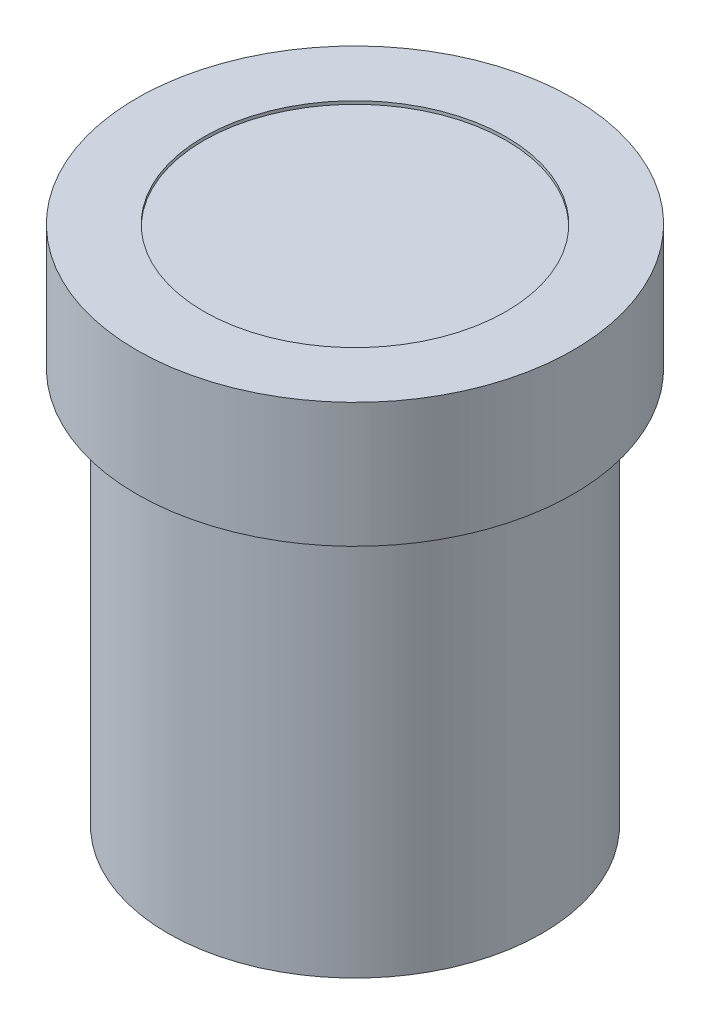
from build123d import *

# Parameters (mm, degrees)
SKETCH1_R           = 6
SKETCH1_R_2         = 2.25
BOSS_EXTRUDE1_DEPTH = 12.7
SKETCH2_R           = 7
SKETCH2_R_2         = 6
SKETCH2_R_3         = 4.85
BOSS_EXTRUDE2_DEPTH = 4
BOSS_EXTRUDE3_START = 3.9
SKETCH2_2_R         = 4.85
BOSS_EXTRUDE3_DEPTH = 0.1


with BuildPart() as part:
    # Sketch1 → Boss-Extrude1 (new body)
    with BuildSketch(Plane(origin=(0, 0, 0), x_dir=(1, 0, 0), z_dir=(0, 1, 0))):
        Circle(SKETCH1_R)
        Circle(SKETCH1_R_2, mode=Mode.SUBTRACT)
    extrude(amount=BOSS_EXTRUDE1_DEPTH)

    # Sketch2 → Boss-Extrude2 (add)
    with BuildSketch(Plane(origin=(0, 12.7, 0), x_dir=(1, 0, 0), z_dir=(0, 1, 0))):
        Circle(SKETCH2_R)
        Circle(SKETCH2_R_2, mode=Mode.SUBTRACT)
        Circle(SKETCH2_R_2)
        Circle(SKETCH2_R_3, mode=Mode.SUBTRACT)
    extrude(amount=BOSS_EXTRUDE2_DEPTH)

    # Sketch2_2 → Boss-Extrude3 (add)
    with BuildSketch(Plane(origin=(0, 12.7, 0), x_dir=(1, 0, 0), z_dir=(0, 1, 0)).offset(BOSS_EXTRUDE3_START)):
        Circle(SKETCH2_2_R)
    extrude(amount=-BOSS_EXTRUDE3_DEPTH)


solid = part.part
